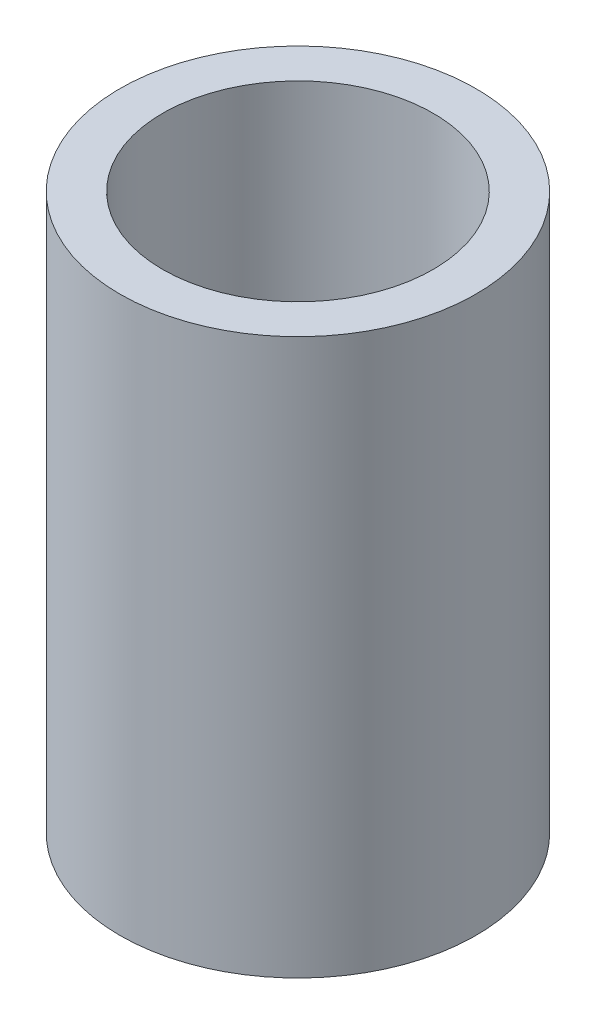
from build123d import *

# Parameters (mm, degrees)
CROQUIS1_R              = 12.5
CROQUIS1_R_2            = 9.5
SALIENTE_EXTRUIR1_DEPTH = 39


with BuildPart() as part:
    # Croquis1 → Saliente-Extruir1 (new body)
    with BuildSketch(Plane(origin=(0, 0, 0), x_dir=(1, 0, 0), z_dir=(0, 1, 0))):
        Circle(CROQUIS1_R)
        Circle(CROQUIS1_R_2, mode=Mode.SUBTRACT)
    extrude(amount=SALIENTE_EXTRUIR1_DEPTH)


solid = part.part
